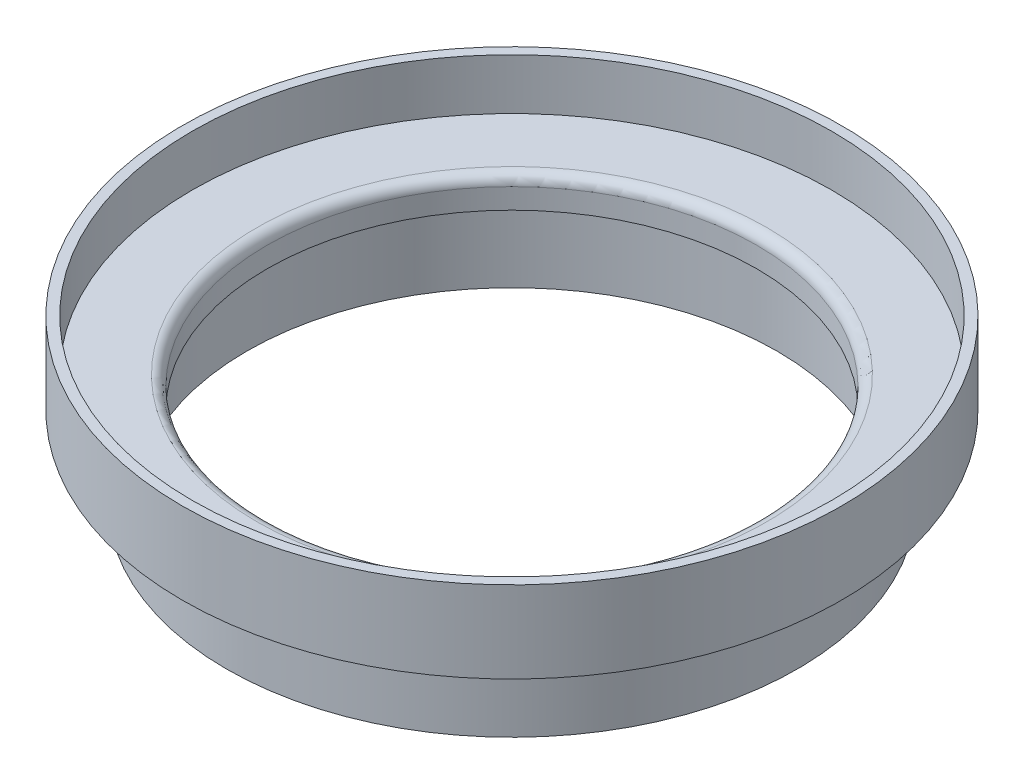
from build123d import *


with BuildPart() as part:
    # Cross Section → Main (revolve)
    with BuildSketch(Plane.XY):
        with BuildLine():
            Line((-38.1, 0), (-38.1, -3.175))
            Line((-38.1, -3.175), (-41.275, -3.175))
            Line((-41.275, -3.175), (-41.275, -15.875))
            Line((-41.275, -15.875), (-44.45, -15.875))
            Line((-44.45, -15.875), (-44.45, -3.175))
            Line((-44.45, -3.175), (-51.308, -3.175))
            Line((-51.308, -3.175), (-51.308, 9.525))
            Line((-51.308, 9.525), (-49.784, 9.525))
            Line((-49.784, 9.525), (-49.784, 1.5875))
            Line((-49.784, 1.5875), (-39.6875, 1.5875))
            ThreePointArc((-39.6875, 1.5875), (-38.564967985, 1.122532015), (-38.1, 0))
        make_face()
    revolve(axis=Axis((0, 55, 0), (0, -1, 0)))


solid = part.part
